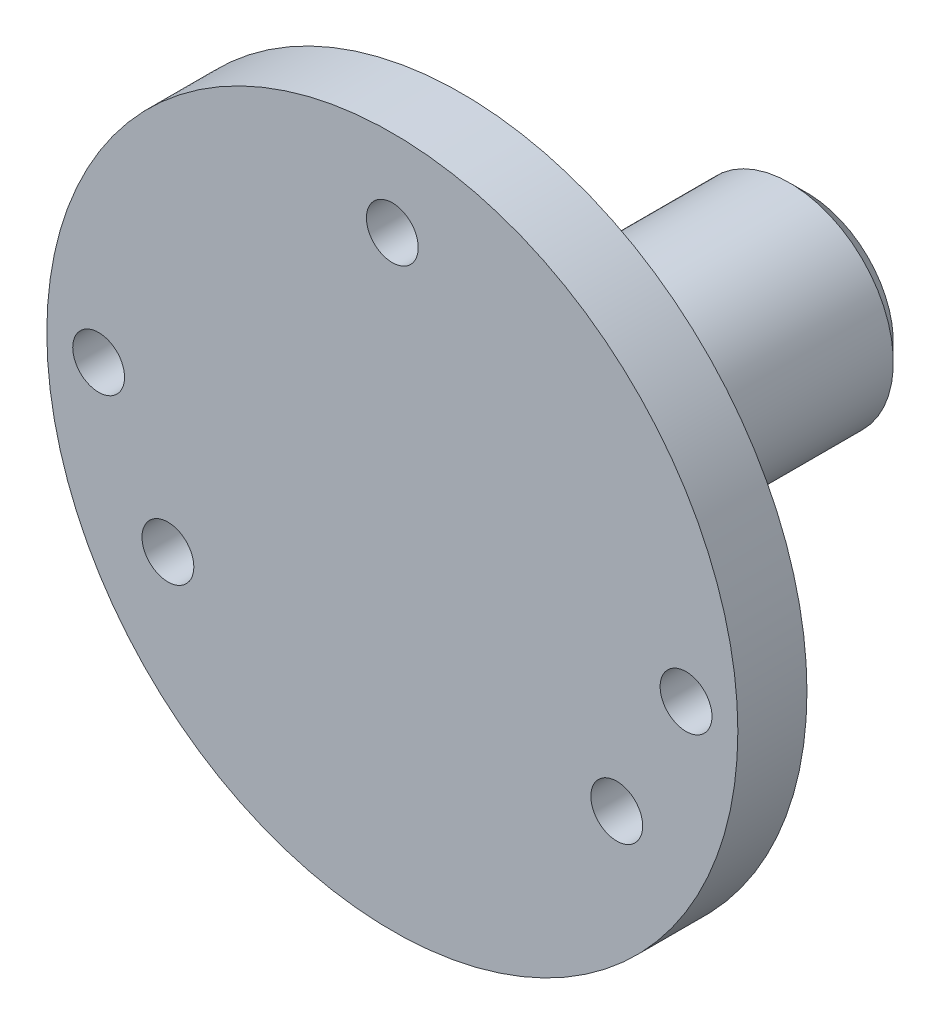
from build123d import *

# Parameters (mm, degrees)
SKETCH1_R           = 10
SKETCH1_R_2         = 5.5
BOSS_EXTRUDE1_DEPTH = 2
SKETCH3_R           = 3
BOSS_EXTRUDE2_DEPTH = 12
SKETCH4_R           = 10
SKETCH4_R_2         = 3
BOSS_EXTRUDE3_DEPTH = 2
CHAMFER2_SIZE       = 1
CHAMFER4_SIZE       = 0.5
CUT_EXTRUDE1_REACH  = 6
SKETCH5_R           = 0.75
SKETCH6_R           = 6.25
SKETCH6_R_2         = 5.5
BOSS_EXTRUDE4_DEPTH = 26
CUT_EXTRUDE2_REACH  = 32
SKETCH7_R           = 0.75
SKETCH9_R           = 17.358770913
CUT_EXTRUDE3_DEPTH  = 28


with BuildPart() as part:
    # Sketch1 → Boss-Extrude1 (new body)
    with BuildSketch(Plane.XY):
        Circle(SKETCH1_R)
        Circle(SKETCH1_R_2, mode=Mode.SUBTRACT)
    extrude(amount=BOSS_EXTRUDE1_DEPTH)



with BuildPart() as body_2:
    # Sketch3 → Boss-Extrude2 (new body)
    with BuildSketch(Plane(origin=(0, 0, 0), x_dir=(-1, 0, 0), z_dir=(0, 0, -1))):
        Circle(SKETCH3_R)
    extrude(amount=BOSS_EXTRUDE2_DEPTH)


with BuildPart() as part_1:
    add(part.part)

    add(body_2.part)  # Boss-Extrude3 merges body 2
    # Sketch4 → Boss-Extrude3 (add)
    with BuildSketch(Plane(origin=(0, 0, 0), x_dir=(-1, 0, 0), z_dir=(0, 0, -1))):
        Circle(SKETCH4_R)
        Circle(SKETCH4_R_2, mode=Mode.SUBTRACT)
    extrude(amount=BOSS_EXTRUDE3_DEPTH)

    # Chamfer2
    chamfer2_edges = [part_1.edges().sort_by_distance(p)[0] for p in [
        (3, 0, -2),
    ]]
    chamfer(chamfer2_edges, length=CHAMFER2_SIZE)

    # Chamfer4
    chamfer4_edges = [part_1.edges().sort_by_distance(p)[0] for p in [
        (3, 0, -12),
    ]]
    chamfer(chamfer4_edges, length=CHAMFER4_SIZE)

    # Sketch5 → Cut-Extrude1 (cut, up to next)
    with BuildSketch(Plane(origin=(0, 0, -2), x_dir=(-1, 0, 0), z_dir=(0, 0, -1)), mode=Mode.PRIVATE) as cut_extrude1_sk1:
        with Locations((-8.5, 0)):
            Circle(SKETCH5_R)
    cut_extrude1_tool1 = extrude(cut_extrude1_sk1.sketch, amount=-CUT_EXTRUDE1_REACH, mode=Mode.PRIVATE) & part_1.part
    add(cut_extrude1_tool1.solids().sort_by_distance((8.5, 0, -2))[0], mode=Mode.SUBTRACT)
    # Sketch5 → Cut-Extrude1 (cut, up to next)
    with BuildSketch(Plane(origin=(0, 0, -2), x_dir=(-1, 0, 0), z_dir=(0, 0, -1)), mode=Mode.PRIVATE) as cut_extrude1_sk2:
        with Locations((8.5, 0)):
            Circle(SKETCH5_R)
    cut_extrude1_tool2 = extrude(cut_extrude1_sk2.sketch, amount=-CUT_EXTRUDE1_REACH, mode=Mode.PRIVATE) & part_1.part
    add(cut_extrude1_tool2.solids().sort_by_distance((-8.5, 0, -2))[0], mode=Mode.SUBTRACT)

    # Sketch6 → Boss-Extrude4 (add)
    with BuildSketch(Plane.XY.offset(2)):
        Circle(SKETCH6_R)
        Circle(SKETCH6_R_2, mode=Mode.SUBTRACT)
    extrude(amount=BOSS_EXTRUDE4_DEPTH)

    # Sketch7 → Cut-Extrude2 (cut, up to next)
    with BuildSketch(Plane(origin=(0, 0, -2), x_dir=(-1, 0, 0), z_dir=(0, 0, -1)), mode=Mode.PRIVATE) as cut_extrude2_sk1:
        with Locations((0, 7.5)):
            Circle(SKETCH7_R)
    cut_extrude2_tool1 = extrude(cut_extrude2_sk1.sketch, amount=-CUT_EXTRUDE2_REACH, mode=Mode.PRIVATE) & part_1.part
    add(cut_extrude2_tool1.solids().sort_by_distance((0, 7.5, -2))[0], mode=Mode.SUBTRACT)
    # Sketch7 → Cut-Extrude2 (cut, up to next)
    with BuildSketch(Plane(origin=(0, 0, -2), x_dir=(-1, 0, 0), z_dir=(0, 0, -1)), mode=Mode.PRIVATE) as cut_extrude2_sk2:
        with Locations((6.495190528, -3.75)):
            Circle(SKETCH7_R)
    cut_extrude2_tool2 = extrude(cut_extrude2_sk2.sketch, amount=-CUT_EXTRUDE2_REACH, mode=Mode.PRIVATE) & part_1.part
    add(cut_extrude2_tool2.solids().sort_by_distance((-6.495191, -3.75, -2))[0], mode=Mode.SUBTRACT)
    # Sketch7 → Cut-Extrude2 (cut, up to next)
    with BuildSketch(Plane(origin=(0, 0, -2), x_dir=(-1, 0, 0), z_dir=(0, 0, -1)), mode=Mode.PRIVATE) as cut_extrude2_sk3:
        with Locations((-6.495190528, -3.75)):
            Circle(SKETCH7_R)
    cut_extrude2_tool3 = extrude(cut_extrude2_sk3.sketch, amount=-CUT_EXTRUDE2_REACH, mode=Mode.PRIVATE) & part_1.part
    add(cut_extrude2_tool3.solids().sort_by_distance((6.495191, -3.75, -2))[0], mode=Mode.SUBTRACT)

    # Sketch9 → Cut-Extrude3 (cut)
    with BuildSketch(Plane.XY.offset(28)):
        Circle(SKETCH9_R)
    extrude(amount=-CUT_EXTRUDE3_DEPTH, mode=Mode.SUBTRACT)


solid = part_1.part
